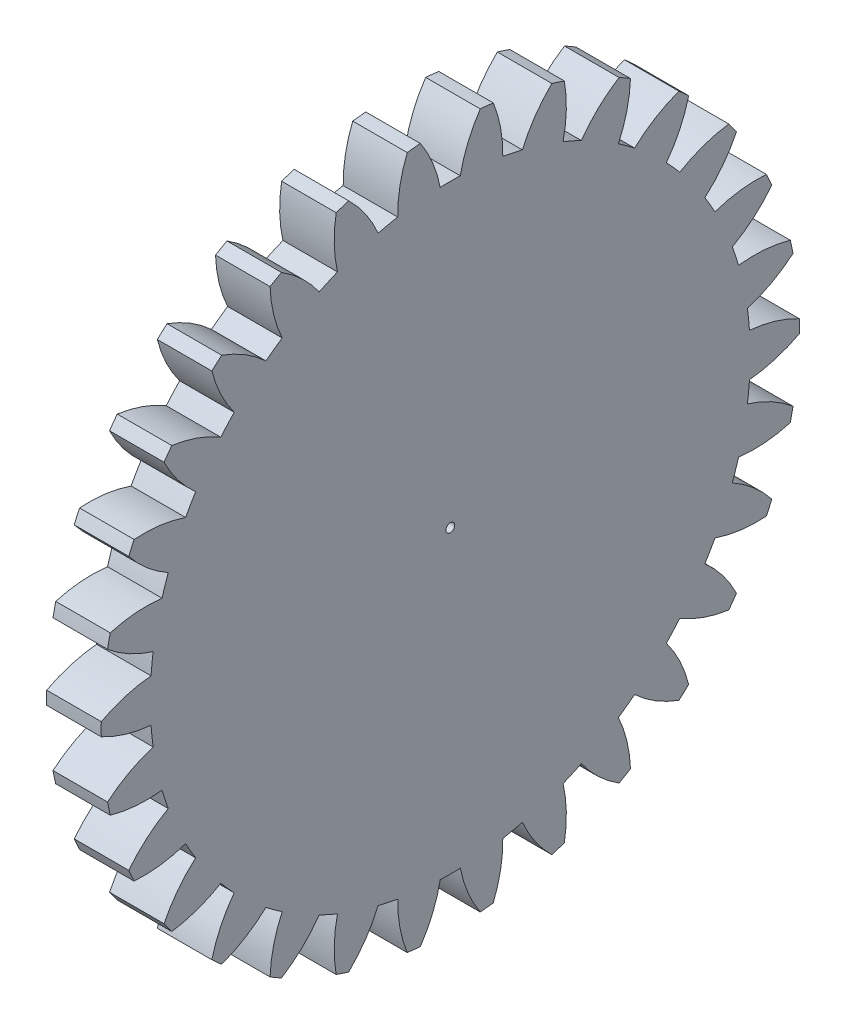
from build123d import *

# Parameters (mm, degrees)
BASPROSKE_W     = 5
BASPROSKE_H     = 32
TOOTHCUT_DEPTH  = 46.530209751
TEETHCUTS_COUNT = 30
TEETHCUTS_ANGLE = 348
BORSKE_R        = 0.4
BORE_DEPTH      = 50.0000508


with BuildPart() as part:
    # BasProSke → Base-Revolve (revolve)
    with BuildSketch(Plane(origin=(0, 0, 0), x_dir=(1, 0, 0), z_dir=(0, 1, 0)), mode=Mode.PRIVATE) as base_revolve_sk:
        with Locations((2.5, 16)):
            Rectangle(BASPROSKE_W, BASPROSKE_H)
    revolve(base_revolve_sk.sketch.rotate(Axis((-10, 0, 0), (1, 0, 0)), 180), axis=Axis((-10, 0, 0), (1, 0, 0)))

    # TooCutSke → ToothCut (cut, through all)
    with BuildSketch(Plane(origin=(0, 0, 0), x_dir=(0, 0, -1), z_dir=(1, 0, 0))):
        with BuildLine():
            ThreePointArc((0.918551563, 27.483654488), (0, 27.499), (-0.918551563, 27.483654488))
            ThreePointArc((-0.918551563, 27.483654488), (-1.617208176, 29.787801627), (-2.761784709, 31.906093311))
            ThreePointArc((-2.761784709, 31.906093311), (0, 32.0254), (2.761784709, 31.906093311))
            ThreePointArc((2.761784709, 31.906093311), (1.617208176, 29.787801627), (0.918551563, 27.483654488))
        make_face()
    toothcut = extrude(amount=TOOTHCUT_DEPTH, mode=Mode.SUBTRACT)

    # TeethCuts: ToothCut ×30 about axis
    teethcuts_axis = Axis((-10, 0, 0), (1, 0, 0))
    for i in range(1, TEETHCUTS_COUNT):
        add(toothcut.rotate(teethcuts_axis, i * TEETHCUTS_ANGLE / (TEETHCUTS_COUNT - 1)), mode=Mode.SUBTRACT)

    # BorSke → Bore (cut, symmetric)
    with BuildSketch(Plane(origin=(0, 0, 0), x_dir=(0, 0, -1), z_dir=(1, 0, 0))):
        with Locations(Location((0, 0, 0), (0, 0, 180))):
            Circle(BORSKE_R)
    extrude(amount=BORE_DEPTH, both=True, mode=Mode.SUBTRACT)


solid = part.part
